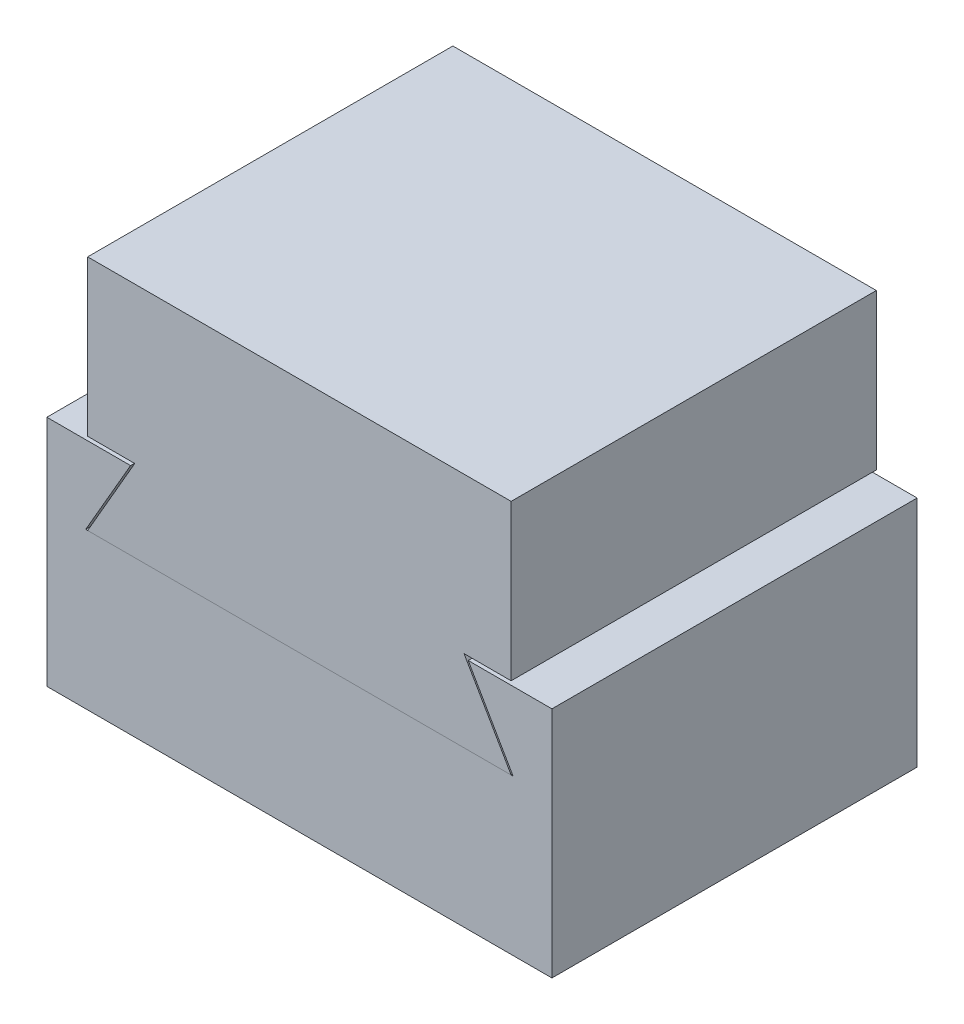
from build123d import *

# Parameters (mm, degrees)
EXTRUDE1_DEPTH = 11.938
EXTRUDE2_DEPTH = 11.938


with BuildPart() as part:
    # Sketch1 → Extrude1 (new body)
    with BuildSketch(Plane.XY):
        Polygon((-6.9215, 0), (6.9215, 0), (5.381706832, 2.667), (6.9215, 2.667), (6.9215, 7.747), (-6.9215, 7.747), (-6.9215, 2.667), (-5.381706832, 2.667), align=None)
    extrude(amount=EXTRUDE1_DEPTH)


with BuildPart() as body_2:
    # Sketch2 → Extrude2 (new body)
    with BuildSketch(Plane.XY):
        Polygon((-6.985, 0), (6.985, 0), (5.518530316, 2.54), (8.255, 2.54), (8.255, -5.08), (-8.255, -5.08), (-8.255, 2.54), (-5.518530316, 2.54), align=None)
    extrude(amount=EXTRUDE2_DEPTH)


solid = Compound([part.part, body_2.part])
